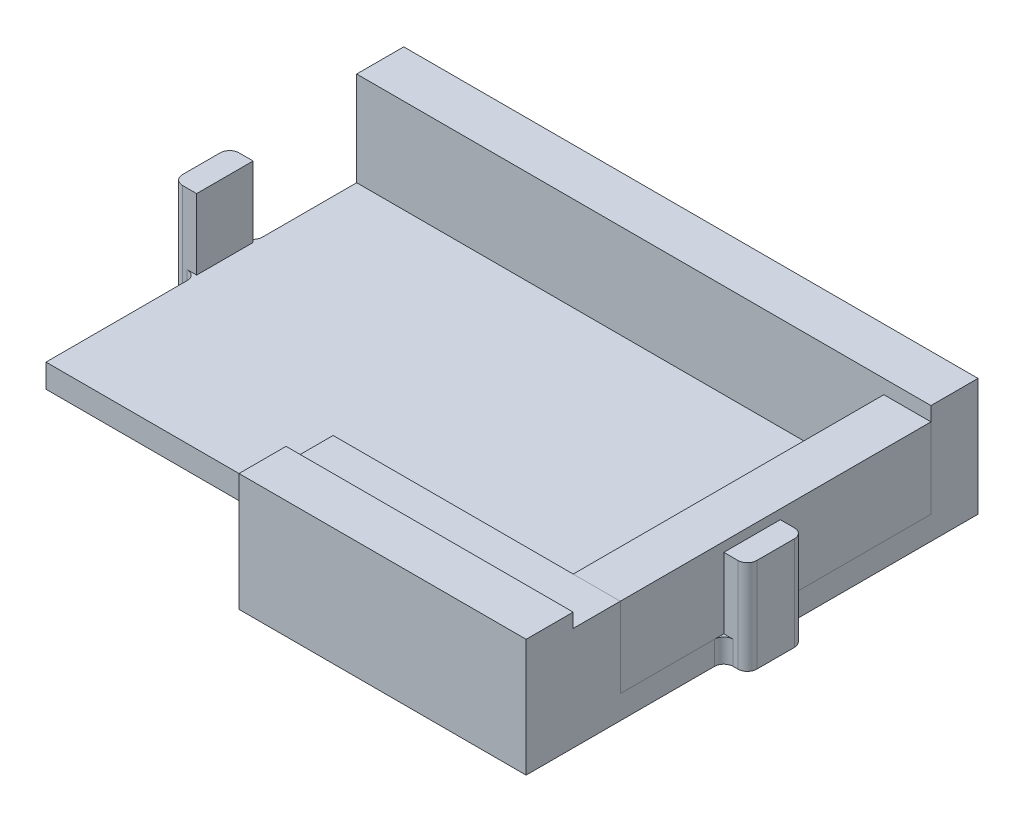
from build123d import *

# Parameters (mm, degrees)
BOSS_EXTRUDE1_DEPTH = 2.5
SKETCH2_W           = 61
SKETCH2_H           = 5
SKETCH2_W_2         = 30.5
BOSS_EXTRUDE2_DEPTH = 10
CUT_EXTRUDE1_DEPTH  = 1
SKETCH5_W           = 2.5
SKETCH5_H           = 6
BOSS_EXTRUDE3_DEPTH = 10
FILLET4_R           = 1
SKETCH6_W           = 30.5
SKETCH6_H           = 5
BOSS_EXTRUDE4_DEPTH = 8.5
SKETCH7_W           = 5
SKETCH7_H           = 33
BOSS_EXTRUDE5_DEPTH = 8.5


with BuildPart() as part:
    # Sketch1 → Boss-Extrude1 (new body)
    with BuildSketch(Plane(origin=(0, 0, 0), x_dir=(1, 0, 0), z_dir=(0, 1, 0))):
        Polygon((0, 10), (30.5, 10), (30.5, 0), (61, 0), (61, 48), (0, 48), align=None)
    extrude(amount=BOSS_EXTRUDE1_DEPTH)

    # Sketch2 → Boss-Extrude2 (add)
    with BuildSketch(Plane(origin=(0, 2.5, 0), x_dir=(1, 0, 0), z_dir=(0, 1, 0))):
        with Locations((30.5, 45.5)):
            Rectangle(SKETCH2_W, SKETCH2_H)
        with Locations((45.75, 2.5)):
            Rectangle(SKETCH2_W_2, SKETCH2_H)
    extrude(amount=BOSS_EXTRUDE2_DEPTH)

    # Sketch3 → Cut-Extrude1 (cut)
    with BuildSketch(Plane.XZ):
        with BuildLine():
            Line((38.1875, -27), (39.6, -27))
            Line((39.6, -27), (39.6, -24.8421875))
            add(Edge.make_bspline(
                [(39.6, -24.8421875), (39.602615405, -24.769084793), (39.607534256, -24.631598895), (39.645917421, -24.438286667), (39.71249642, -24.273057168), (39.80650625, -24.137413973), (39.920250057, -24.03091493), (40.049992557, -23.954750809), (40.194402262, -23.908778619), (40.294972194, -23.902988305), (40.346875, -23.9)],
                knots=[0, 0, 0, 0, 0.000219202, 0.000412257, 0.000588099, 0.000749771, 0.000903445, 0.001051907, 0.001197689, 0.001353164, 0.001353164, 0.001353164, 0.001353164], degree=3))
            add(Edge.make_bspline(
                [(40.346875, -23.9), (40.400811886, -23.903069829), (40.505370426, -23.9090208), (40.654616604, -23.95331831), (40.785818729, -24.030620386), (40.898267418, -24.137525593), (40.989912112, -24.272508914), (41.055867465, -24.436263579), (41.094160201, -24.627408298), (41.097981983, -24.763877569), (41.1, -24.8359375)],
                knots=[0, 0, 0, 0, 0.000161694, 0.00031345, 0.000461912, 0.000614446, 0.000775232, 0.000947589, 0.001140645, 0.001356632, 0.001356632, 0.001356632, 0.001356632], degree=3))
            Line((41.1, -24.8359375), (41.1, -30.7484375))
            add(Edge.make_bspline(
                [(41.1, -30.7484375), (41.099564666, -30.789608087), (41.098725346, -30.868984644), (41.087679787, -30.98393408), (41.069116088, -31.089395785), (41.044395541, -31.186415943), (41.011489006, -31.273687026), (40.972763577, -31.35292309), (40.925545184, -31.42249894), (40.851306001, -31.502978541), (40.733925262, -31.585343097), (40.562936526, -31.653276145), (40.358565351, -31.693106891), (40.211651668, -31.697592735), (40.1328125, -31.7)],
                knots=[0, 0, 0, 0, 0.000123477, 0.000238063, 0.000345954, 0.000444491, 0.000537941, 0.000625288, 0.000708497, 0.00078922, 0.000952693, 0.001133464, 0.001337549, 0.001573905, 0.001573905, 0.001573905, 0.001573905], degree=3))
            Line((40.1328125, -31.7), (38.1734375, -31.7))
            add(Edge.make_bspline(
                [(38.1734375, -31.7), (38.103112581, -31.700035372), (37.96658071, -31.700104044), (37.768157568, -31.691054163), (37.58205737, -31.681244136), (37.408685819, -31.664781958), (37.247289379, -31.647623515), (37.099076931, -31.62146964), (36.962560228, -31.594754723), (36.876957605, -31.570836449), (36.8359375, -31.559375)],
                knots=[0, 0, 0, 0, 0.000210943, 0.000409535, 0.000595793, 0.000769933, 0.000931959, 0.001082487, 0.001221304, 0.001349028, 0.001349028, 0.001349028, 0.001349028], degree=3))
            add(Edge.make_bspline(
                [(36.8359375, -31.559375), (36.758174787, -31.535693231), (36.605197894, -31.48910582), (36.390091341, -31.388381046), (36.189773634, -31.269615451), (36.006592335, -31.12861923), (35.842172885, -30.96773624), (35.699559897, -30.788048857), (35.576231309, -30.592456035), (35.474550885, -30.379737692), (35.397163841, -30.150698292), (35.341005355, -29.908428323), (35.305483612, -29.652613392), (35.301855407, -29.477202426), (35.3, -29.3875)],
                knots=[0, 0, 0, 0, 0.000243595, 0.000479206, 0.000710461, 0.000941103, 0.001170924, 0.00139884, 0.001627734, 0.001863257, 0.002104389, 0.002351501, 0.002608498, 0.002877471, 0.002877471, 0.002877471, 0.002877471], degree=3))
            add(Edge.make_bspline(
                [(35.3, -29.3875), (35.301809825, -29.292586825), (35.30533284, -29.107828413), (35.341011258, -28.839627251), (35.395696925, -28.588344436), (35.476429153, -28.355502686), (35.577363674, -28.139551849), (35.704023887, -27.942951805), (35.851833656, -27.762963601), (36.023207918, -27.601603438), (36.217200455, -27.458365944), (36.433788728, -27.334655233), (36.673512874, -27.232454742), (36.933425896, -27.145634461), (37.216328859, -27.081746386), (37.519917531, -27.032769881), (37.84636014, -27.005079255), (38.071303311, -27.001730061), (38.1875, -27)],
                knots=[0, 0, 0, 0, 0.000284585, 0.000553975, 0.000810225, 0.00105482, 0.001291754, 0.001523642, 0.001754511, 0.001988834, 0.002227902, 0.002476359, 0.002735282, 0.003008523, 0.003297327, 0.003604298, 0.003930513, 0.004279076, 0.004279076, 0.004279076, 0.004279076], degree=3))
        make_face()
        with BuildLine():
            Line((38.5609375, -30.5), (39.6, -30.5))
            Line((39.6, -30.5), (39.6, -28.2))
            Line((39.6, -28.2), (38.5609375, -28.2))
            add(Edge.make_bspline(
                [(38.5609375, -28.2), (38.473925807, -28.201685184), (38.306945409, -28.204919149), (38.067107498, -28.224188963), (37.84970512, -28.25980799), (37.65410835, -28.309033712), (37.480223381, -28.3740791), (37.327553707, -28.457520614), (37.19637362, -28.559225985), (37.088067853, -28.680511212), (37.001621577, -28.82004504), (36.943027083, -28.981175779), (36.906595982, -29.161394296), (36.902263617, -29.288352923), (36.9, -29.3546875)],
                knots=[0, 0, 0, 0, 0.000261054, 0.000500978, 0.000721119, 0.000921217, 0.001105194, 0.001276535, 0.001441259, 0.001600603, 0.001761927, 0.00193054, 0.002112254, 0.002311084, 0.002311084, 0.002311084, 0.002311084], degree=3))
            add(Edge.make_bspline(
                [(36.9, -29.3546875), (36.903364233, -29.434236925), (36.909848384, -29.587558781), (36.966431543, -29.805808259), (37.057238421, -30.003435042), (37.149400887, -30.111694511), (37.1953125, -30.165625)],
                knots=[0, 0, 0, 0, 0.000238239, 0.000459177, 0.000672331, 0.000883921, 0.000883921, 0.000883921, 0.000883921], degree=3))
            add(Edge.make_bspline(
                [(37.1953125, -30.165625), (37.225735979, -30.19276864), (37.290030891, -30.250132162), (37.408815453, -30.317269388), (37.54843091, -30.373136489), (37.708729079, -30.419369207), (37.890973375, -30.456831222), (38.095231339, -30.482248599), (38.321103054, -30.498011146), (38.47861699, -30.499317348), (38.5609375, -30.5)],
                knots=[0, 0, 0, 0, 0.000122035, 0.000257901, 0.000406462, 0.000572587, 0.000757676, 0.00096408, 0.001189621, 0.001436541, 0.001436541, 0.001436541, 0.001436541], degree=3))
        make_face(mode=Mode.SUBTRACT)
        with BuildLine():
            add(Edge.make_bspline(
                [(27.3953125, -26.4515625), (27.397434395, -26.389433762), (27.401815522, -26.261155035), (27.438676119, -26.066027702), (27.49508646, -25.862986158), (27.575462199, -25.654509555), (27.676999221, -25.441216064), (27.810927351, -25.232591398), (27.966003207, -25.022936194), (28.147847897, -24.817903952), (28.356369794, -24.622072842), (28.59422462, -24.445271264), (28.857924229, -24.287111598), (29.147826391, -24.149406865), (29.463719448, -24.035657986), (29.807343765, -23.957565551), (30.175103983, -23.907880656), (30.428998104, -23.902673778), (30.559375, -23.9)],
                knots=[0, 0, 0, 0, 0.000186259, 0.000384573, 0.000593838, 0.000817864, 0.001054066, 0.001301178, 0.001560242, 0.001835849, 0.002122179, 0.002416867, 0.002723153, 0.003043252, 0.003378327, 0.003728149, 0.004098518, 0.004489455, 0.004489455, 0.004489455, 0.004489455], degree=3))
            add(Edge.make_bspline(
                [(30.559375, -23.9), (30.658907566, -23.900818023), (30.853542013, -23.902417653), (31.138651795, -23.926098172), (31.410314201, -23.958436313), (31.668437928, -24.009492265), (31.91383369, -24.073164845), (32.148411511, -24.150895125), (32.370734316, -24.246731815), (32.582544659, -24.358413872), (32.786445998, -24.485270243), (32.979262764, -24.63299341), (33.165986579, -24.797359597), (33.279688705, -24.920302684), (33.3375, -24.9828125)],
                knots=[0, 0, 0, 0, 0.000298503, 0.000583718, 0.000857758, 0.00111884, 0.001372379, 0.001617951, 0.001859431, 0.002097763, 0.002335766, 0.002578894, 0.002825695, 0.003080976, 0.003080976, 0.003080976, 0.003080976], degree=3))
            add(Edge.make_bspline(
                [(33.3375, -24.9828125), (33.387732238, -25.045256239), (33.488415919, -25.170416213), (33.62664404, -25.369767653), (33.751305978, -25.581322722), (33.864560031, -25.802969389), (33.96889525, -26.032668078), (34.057049874, -26.271575372), (34.132994172, -26.518144216), (34.192776415, -26.77262262), (34.24219802, -27.034713776), (34.275782698, -27.304499098), (34.296930981, -27.58246952), (34.298966516, -27.770273188), (34.3, -27.865625)],
                knots=[0, 0, 0, 0, 0.000240371, 0.000481791, 0.000726984, 0.000976461, 0.001228237, 0.001483351, 0.001739872, 0.002001749, 0.002267144, 0.002539633, 0.002816941, 0.003102946, 0.003102946, 0.003102946, 0.003102946], degree=3))
            add(Edge.make_bspline(
                [(34.3, -27.865625), (34.296928776, -28.018393355), (34.290935568, -28.316506669), (34.237641938, -28.750738581), (34.155057159, -29.161415944), (34.034040456, -29.546173325), (33.88237364, -29.905712762), (33.700578841, -30.238948675), (33.488694914, -30.545554745), (33.247756976, -30.823816255), (32.981430376, -31.072732337), (32.692976857, -31.291699142), (32.381102483, -31.475879662), (32.05203128, -31.631243154), (31.706067235, -31.751129862), (31.347662006, -31.837256518), (30.978149733, -31.890278039), (30.727778247, -31.896741619), (30.6015625, -31.9)],
                knots=[0, 0, 0, 0, 0.000458135, 0.000894008, 0.001310458, 0.001713222, 0.002101811, 0.002479406, 0.002849985, 0.003217754, 0.003581454, 0.003941769, 0.004301917, 0.004666091, 0.005031762, 0.005398231, 0.005770569, 0.006149084, 0.006149084, 0.006149084, 0.006149084], degree=3))
            add(Edge.make_bspline(
                [(30.6015625, -31.9), (30.524441789, -31.898742886), (30.37209357, -31.896259519), (30.146868459, -31.878236684), (29.927344507, -31.851668844), (29.715127789, -31.807665956), (29.508340081, -31.757818429), (29.309085734, -31.692186568), (29.115241089, -31.618473757), (28.929616127, -31.530224099), (28.752874019, -31.433744499), (28.58541226, -31.332208627), (28.428296632, -31.226138053), (28.282641161, -31.112876748), (28.146773866, -30.995181346), (28.023157809, -30.870413965), (27.907947472, -30.742735672), (27.806217947, -30.608384363), (27.713796985, -30.473947596), (27.635979163, -30.338426372), (27.567750702, -30.206018755), (27.513878594, -30.074398002), (27.468222606, -29.946218289), (27.43961528, -29.818620064), (27.419205469, -29.693361827), (27.416809536, -29.609975649), (27.415625, -29.56875)],
                knots=[0, 0, 0, 0, 0.000231334, 0.00045699, 0.000677541, 0.000894188, 0.001106785, 0.001315308, 0.001523067, 0.001728564, 0.001931328, 0.002126947, 0.002315899, 0.002499671, 0.002680172, 0.002854739, 0.00302628, 0.003195665, 0.003359913, 0.003515349, 0.003664189, 0.003806376, 0.003941765, 0.004071763, 0.004198161, 0.004321757, 0.004321757, 0.004321757, 0.004321757], degree=3))
            add(Edge.make_bspline(
                [(27.415625, -29.56875), (27.418216573, -29.525307673), (27.423326947, -29.439642884), (27.458565709, -29.31483296), (27.519738515, -29.199264042), (27.601639003, -29.094485493), (27.700373583, -29.005106438), (27.812919531, -28.94061161), (27.935086452, -28.898330021), (28.020481916, -28.894263038), (28.0640625, -28.8921875)],
                knots=[0, 0, 0, 0, 0.000130289, 0.000256919, 0.00038551, 0.00052022, 0.000654131, 0.000782237, 0.000907247, 0.001037535, 0.001037535, 0.001037535, 0.001037535], degree=3))
            add(Edge.make_bspline(
                [(28.0640625, -28.8921875), (28.11106611, -28.893946378), (28.200179439, -28.897281004), (28.324887939, -28.922962447), (28.43172227, -28.968196434), (28.520138472, -29.036800167), (28.598928401, -29.127534222), (28.680965048, -29.239061767), (28.76480885, -29.378834016), (28.82022041, -29.481020091), (28.85, -29.5359375)],
                knots=[0, 0, 0, 0, 0.000140937, 0.0002672, 0.000379841, 0.000485781, 0.000599715, 0.000739408, 0.000900732, 0.00108816, 0.00108816, 0.00108816, 0.00108816], degree=3))
            add(Edge.make_bspline(
                [(28.85, -29.5359375), (28.901211449, -29.62825275), (29.000008605, -29.806347382), (29.17412368, -30.045485691), (29.362747316, -30.247263649), (29.564423253, -30.415768884), (29.788184683, -30.545230891), (30.034861588, -30.636014618), (30.305541211, -30.689354721), (30.49350599, -30.696373491), (30.590625, -30.7)],
                knots=[0, 0, 0, 0, 0.000316494, 0.00061058, 0.000884727, 0.001143409, 0.001396133, 0.001656185, 0.001928603, 0.002219832, 0.002219832, 0.002219832, 0.002219832], degree=3))
            add(Edge.make_bspline(
                [(30.590625, -30.7), (30.668904848, -30.698261598), (30.82268842, -30.694846445), (31.04630224, -30.65733031), (31.25832523, -30.59983937), (31.457865159, -30.518199368), (31.645312593, -30.412783723), (31.819870085, -30.282917498), (31.983147995, -30.131118747), (32.131501037, -29.954683731), (32.265655206, -29.757941294), (32.383149221, -29.541347392), (32.482331498, -29.304856673), (32.560445287, -29.048469195), (32.623417413, -28.772809997), (32.668074561, -28.477773945), (32.694558587, -28.162986086), (32.69815336, -27.946927256), (32.7, -27.8359375)],
                knots=[0, 0, 0, 0, 0.00023463, 0.000460939, 0.000678149, 0.000892576, 0.001105959, 0.00132159, 0.0015438, 0.001773275, 0.002011637, 0.002257049, 0.002511257, 0.002779611, 0.003060101, 0.003358869, 0.003674053, 0.004006998, 0.004006998, 0.004006998, 0.004006998], degree=3))
            add(Edge.make_bspline(
                [(32.7, -27.8359375), (32.698833253, -27.760931136), (32.69655527, -27.614486963), (32.686542363, -27.399076416), (32.665280534, -27.193891054), (32.640015517, -26.997520446), (32.603466249, -26.811507385), (32.56041258, -26.635005369), (32.508120395, -26.468274026), (32.449927797, -26.310651199), (32.381075769, -26.16367205), (32.310818082, -26.023934919), (32.230340137, -25.89514944), (32.143127881, -25.776982149), (32.04986706, -25.667643547), (31.950588506, -25.567776514), (31.843489711, -25.478402803), (31.693281427, -25.371883839), (31.489732233, -25.262067222), (31.225379638, -25.167679785), (30.94102803, -25.109994376), (30.744546838, -25.103388752), (30.64375, -25.1)],
                knots=[0, 0, 0, 0, 0.000225049, 0.000439391, 0.000646638, 0.000843749, 0.001033127, 0.00121503, 0.001388495, 0.001557108, 0.001718621, 0.001875159, 0.002026044, 0.002173549, 0.002315401, 0.002456823, 0.002595463, 0.002733327, 0.003008793, 0.00328606, 0.00357288, 0.003875025, 0.003875025, 0.003875025, 0.003875025], degree=3))
            add(Edge.make_bspline(
                [(30.64375, -25.1), (30.588489942, -25.100593687), (30.479768196, -25.10176174), (30.320612286, -25.120042027), (30.167791943, -25.146807154), (30.020831754, -25.181431319), (29.881027725, -25.230719935), (29.748093101, -25.290387087), (29.620719037, -25.359159796), (29.500104525, -25.438731593), (29.387498939, -25.530229656), (29.281140777, -25.630630295), (29.180145082, -25.7394719), (29.090208217, -25.861250123), (29.005084319, -25.991365687), (28.927399639, -26.131868605), (28.856565342, -26.282083188), (28.816988353, -26.387202497), (28.796875, -26.440625)],
                knots=[0, 0, 0, 0, 0.000165691, 0.00032599, 0.000479863, 0.000631071, 0.000778327, 0.000923808, 0.001067838, 0.001212147, 0.001356609, 0.001502516, 0.001650715, 0.001801341, 0.00195606, 0.002116929, 0.002282591, 0.002453783, 0.002453783, 0.002453783, 0.002453783], degree=3))
            add(Edge.make_bspline(
                [(28.796875, -26.440625), (28.779923737, -26.49039154), (28.747176989, -26.586531418), (28.687691881, -26.720620223), (28.623103662, -26.841257823), (28.553013155, -26.948413623), (28.467251361, -27.040271656), (28.354687836, -27.10142068), (28.221471962, -27.137410906), (28.125771742, -27.141552673), (28.075, -27.14375)],
                knots=[0, 0, 0, 0, 0.000157658, 0.000304566, 0.000439494, 0.000567771, 0.000688206, 0.000812048, 0.000946623, 0.0010987, 0.0010987, 0.0010987, 0.0010987], degree=3))
            add(Edge.make_bspline(
                [(28.075, -27.14375), (28.029903738, -27.141508843), (27.941198654, -27.137100449), (27.814095489, -27.097167016), (27.695459856, -27.036124439), (27.592900486, -26.94770771), (27.503846104, -26.84423332), (27.441625361, -26.723661053), (27.401582242, -26.591574897), (27.397448484, -26.499262112), (27.3953125, -26.4515625)],
                knots=[0, 0, 0, 0, 0.000134955, 0.000265459, 0.000396159, 0.000532599, 0.000669038, 0.000803231, 0.000936731, 0.001079467, 0.001079467, 0.001079467, 0.001079467], degree=3))
        make_face()
        with BuildLine():
            Line((22.609375, -24), (24.95625, -24))
            add(Edge.make_bspline(
                [(24.95625, -24), (24.997415558, -24.00044181), (25.076263915, -24.001288052), (25.190254306, -24.012085866), (25.294261467, -24.031717368), (25.390986138, -24.053200458), (25.477078179, -24.087562104), (25.555956611, -24.125038751), (25.62369368, -24.17349785), (25.705027455, -24.244824252), (25.786617851, -24.360816671), (25.853445579, -24.530393885), (25.892921937, -24.732596084), (25.897538073, -24.878457572), (25.9, -24.95625)],
                knots=[0, 0, 0, 0, 0.000123477, 0.000236507, 0.000342861, 0.000441013, 0.000533001, 0.000620348, 0.000702271, 0.000781943, 0.00094415, 0.001121437, 0.001325521, 0.001558758, 0.001558758, 0.001558758, 0.001558758], degree=3))
            Line((25.9, -24.95625), (25.9, -30.74375))
            add(Edge.make_bspline(
                [(25.9, -30.74375), (25.897849137, -30.823174119), (25.893850401, -30.970833982), (25.851264008, -31.174607226), (25.784726551, -31.345849509), (25.682049495, -31.481443137), (25.547883107, -31.584300205), (25.37896778, -31.651640477), (25.178606033, -31.693462879), (25.033573246, -31.697726747), (24.95625, -31.7)],
                knots=[0, 0, 0, 0, 0.000237916, 0.000442317, 0.000621644, 0.000784459, 0.000946033, 0.001122478, 0.00132535, 0.001557027, 0.001557027, 0.001557027, 0.001557027], degree=3))
            Line((24.95625, -31.7), (22.46875, -31.7))
            add(Edge.make_bspline(
                [(22.46875, -31.7), (22.380195084, -31.699016417), (22.209243581, -31.697117653), (21.961598382, -31.684980581), (21.732143127, -31.663431667), (21.51900852, -31.632807584), (21.320018105, -31.589552454), (21.133341895, -31.529839763), (20.956539538, -31.455218626), (20.846817504, -31.392276194), (20.7921875, -31.3609375)],
                knots=[0, 0, 0, 0, 0.000265666, 0.000512858, 0.000743584, 0.000956824, 0.001158502, 0.001353689, 0.001544083, 0.001732881, 0.001732881, 0.001732881, 0.001732881], degree=3))
            add(Edge.make_bspline(
                [(20.7921875, -31.3609375), (20.746859819, -31.332552516), (20.65620876, -31.275785243), (20.530170425, -31.176793863), (20.411485761, -31.067709117), (20.301206611, -30.948440861), (20.201696205, -30.819051469), (20.113725938, -30.682710597), (20.038552778, -30.539936674), (19.9755159, -30.39122794), (19.927319562, -30.236725481), (19.893400873, -30.077676468), (19.86982407, -29.914766049), (19.868072242, -29.804251604), (19.8671875, -29.7484375)],
                knots=[0, 0, 0, 0, 0.000160352, 0.00032069, 0.000479927, 0.000643579, 0.000807344, 0.000969008, 0.001129763, 0.001290822, 0.001452916, 0.001614429, 0.001778395, 0.001945699, 0.001945699, 0.001945699, 0.001945699], degree=3))
            add(Edge.make_bspline(
                [(19.8671875, -29.7484375), (19.870692334, -29.654400526), (19.877531182, -29.470909822), (19.933683369, -29.205969805), (20.024066425, -28.960027801), (20.154910751, -28.735520326), (20.321165278, -28.529771878), (20.525259912, -28.345168119), (20.764690162, -28.179226249), (20.943500543, -28.090948264), (21.0359375, -28.0453125)],
                knots=[0, 0, 0, 0, 0.000281874, 0.00055001, 0.000808598, 0.00106481, 0.001325916, 0.001599086, 0.001887742, 0.002196663, 0.002196663, 0.002196663, 0.002196663], degree=3))
            add(Edge.make_bspline(
                [(21.0359375, -28.0453125), (20.973698003, -28.02467476), (20.852230585, -27.984397878), (20.67828039, -27.913252976), (20.515311339, -27.837497473), (20.364676165, -27.753142363), (20.227017994, -27.660166577), (20.099479567, -27.562302095), (19.985422759, -27.455642433), (19.882821782, -27.34231557), (19.792280825, -27.222104467), (19.713097522, -27.094805268), (19.648309964, -26.95964993), (19.591912181, -26.818800434), (19.553102419, -26.668797324), (19.520366123, -26.513198889), (19.504051782, -26.349824039), (19.501365307, -26.239089474), (19.5, -26.1828125)],
                knots=[0, 0, 0, 0, 0.000196664, 0.000383812, 0.000563445, 0.000735547, 0.000901091, 0.001061429, 0.001217311, 0.001368873, 0.001519499, 0.001668232, 0.001817776, 0.00196866, 0.002122556, 0.002281901, 0.002445307, 0.002614173, 0.002614173, 0.002614173, 0.002614173], degree=3))
            add(Edge.make_bspline(
                [(19.5, -26.1828125), (19.503461017, -26.078793647), (19.510295392, -25.873390428), (19.577916521, -25.574954709), (19.680478222, -25.290689567), (19.828282828, -25.027648393), (20.01054828, -24.788969357), (20.223389643, -24.580143173), (20.466711789, -24.404811205), (20.647447054, -24.318666901), (20.7390625, -24.275)],
                knots=[0, 0, 0, 0, 0.0003116, 0.000615309, 0.000913402, 0.001215563, 0.001516514, 0.001811529, 0.002107234, 0.002411219, 0.002411219, 0.002411219, 0.002411219], degree=3))
            add(Edge.make_bspline(
                [(20.7390625, -24.275), (20.799670964, -24.250654322), (20.923446966, -24.200935019), (21.119452541, -24.142151292), (21.327917118, -24.095542104), (21.550380522, -24.060367094), (21.788509127, -24.031603193), (22.045648513, -24.01451212), (22.3212055, -24.000714391), (22.511438019, -24.000242792), (22.609375, -24)],
                knots=[0, 0, 0, 0, 0.000195868, 0.000400006, 0.00061304, 0.000836264, 0.001075423, 0.001332359, 0.001609203, 0.00190297, 0.00190297, 0.00190297, 0.00190297], degree=3))
        make_face()
        with BuildLine():
            Line((22.7546875, -27.4), (24.4, -27.4))
            Line((24.4, -27.4), (24.4, -25.2))
            Line((24.4, -25.2), (22.7015625, -25.2))
            add(Edge.make_bspline(
                [(22.7015625, -25.2), (22.636960258, -25.200986697), (22.511797831, -25.202898354), (22.330224186, -25.215098838), (22.161051944, -25.236506353), (22.004068057, -25.268094391), (21.859328646, -25.306612649), (21.726069456, -25.352570319), (21.60797199, -25.411598943), (21.499334317, -25.474753655), (21.405751026, -25.550623204), (21.323727607, -25.633772569), (21.253278307, -25.725586969), (21.198095328, -25.827322133), (21.152893651, -25.93708658), (21.122634393, -26.055966699), (21.103312621, -26.183222172), (21.101122499, -26.270759598), (21.1, -26.315625)],
                knots=[0, 0, 0, 0, 0.000193807, 0.000375487, 0.000545649, 0.000704993, 0.000855465, 0.000994834, 0.001126909, 0.001250978, 0.001371037, 0.001487052, 0.001600803, 0.001716902, 0.001833254, 0.001956047, 0.002083991, 0.002218511, 0.002218511, 0.002218511, 0.002218511], degree=3))
            add(Edge.make_bspline(
                [(21.1, -26.315625), (21.100918247, -26.361559449), (21.102701925, -26.45078631), (21.12455026, -26.579321889), (21.154243394, -26.699068274), (21.200228922, -26.808598692), (21.26045565, -26.907048509), (21.331157689, -26.997968126), (21.41621538, -27.077645787), (21.514602046, -27.147444096), (21.626628063, -27.205245528), (21.748964547, -27.259961896), (21.886078313, -27.302656472), (22.035457789, -27.338174392), (22.197245874, -27.36607614), (22.371403958, -27.386717839), (22.558741209, -27.396598962), (22.688012701, -27.398842726), (22.7546875, -27.4)],
                knots=[0, 0, 0, 0, 0.000137642, 0.000267367, 0.00039016, 0.000507108, 0.000622066, 0.000735538, 0.000851595, 0.000970386, 0.001096214, 0.001229164, 0.001371968, 0.001526213, 0.00168959, 0.001864213, 0.002052031, 0.002252086, 0.002252086, 0.002252086, 0.002252086], degree=3))
        make_face(mode=Mode.SUBTRACT)
        with BuildLine():
            Line((24.4, -30.5), (24.4, -28.5))
            Line((24.4, -28.5), (22.9515625, -28.5))
            add(Edge.make_bspline(
                [(22.9515625, -28.5), (22.858796315, -28.500722054), (22.683904339, -28.502083342), (22.438614122, -28.524429591), (22.226048411, -28.557188245), (22.043688346, -28.604703837), (21.885532563, -28.672434831), (21.751561104, -28.76811269), (21.635091924, -28.887969958), (21.576861926, -28.983577247), (21.546875, -29.0328125)],
                knots=[0, 0, 0, 0, 0.000278195, 0.000524481, 0.000738201, 0.000922795, 0.001088582, 0.001251149, 0.001413597, 0.001586074, 0.001586074, 0.001586074, 0.001586074], degree=3))
            add(Edge.make_bspline(
                [(21.546875, -29.0328125), (21.525855906, -29.07027428), (21.483996925, -29.144878444), (21.442815471, -29.267652577), (21.414358889, -29.396077388), (21.412088661, -29.484733047), (21.4109375, -29.5296875)],
                knots=[0, 0, 0, 0, 0.000128591, 0.000256086, 0.000386935, 0.000521537, 0.000521537, 0.000521537, 0.000521537], degree=3))
            add(Edge.make_bspline(
                [(21.4109375, -29.5296875), (21.411837646, -29.57665573), (21.413557483, -29.666394103), (21.434794111, -29.794758858), (21.466882615, -29.911008904), (21.512553098, -30.016103823), (21.571737287, -30.108862221), (21.645633752, -30.18873812), (21.732142536, -30.256308628), (21.832864846, -30.311294452), (21.946751108, -30.35589558), (22.073274986, -30.394531848), (22.213647079, -30.427629539), (22.367803007, -30.452816228), (22.535414186, -30.475892536), (22.716536468, -30.488203364), (22.911339088, -30.498589694), (23.045815945, -30.499518067), (23.115625, -30.5)],
                knots=[0, 0, 0, 0, 0.000140764, 0.000268946, 0.000389137, 0.000501778, 0.000611431, 0.000717589, 0.000826674, 0.000939282, 0.001060565, 0.001193018, 0.0013359, 0.001492851, 0.001661464, 0.001843258, 0.002037235, 0.002246633, 0.002246633, 0.002246633, 0.002246633], degree=3))
            Line((23.115625, -30.5), (24.4, -30.5))
        make_face(mode=Mode.SUBTRACT)
    extrude(amount=-CUT_EXTRUDE1_DEPTH, mode=Mode.SUBTRACT)

    # Sketch5 → Boss-Extrude3 (add)
    with BuildSketch(Plane.XZ):
        with Locations((-1.25, -29)):
            Rectangle(SKETCH5_W, SKETCH5_H)
        with Locations((62.25, -24)):
            Rectangle(SKETCH5_W, SKETCH5_H)
    extrude(amount=-BOSS_EXTRUDE3_DEPTH)

    # Fillet4
    fillet4_edges = [part.edges().sort_by_distance(p)[0] for p in [
        (0, 1.25, -26),
        (0, 1.25, -32),
        (-2.5, 5, -32),
        (-2.5, 5, -26),
        (61, 1.25, -27),
        (61, 1.25, -21),
        (63.5, 5, -21),
        (63.5, 5, -27),
    ]]
    fillet(fillet4_edges, radius=FILLET4_R)

    # Sketch6 → Boss-Extrude4 (add)
    with BuildSketch(Plane(origin=(0, 2.5, 0), x_dir=(1, 0, 0), z_dir=(0, 1, 0))):
        with Locations((45.75, 7.5)):
            Rectangle(SKETCH6_W, SKETCH6_H)
    extrude(amount=BOSS_EXTRUDE4_DEPTH)


with BuildPart() as body_2:
    # Sketch7 → Boss-Extrude5 (new body)
    with BuildSketch(Plane(origin=(0, 2.5, 0), x_dir=(1, 0, 0), z_dir=(0, 1, 0))):
        with Locations((58.5, 26.5)):
            Rectangle(SKETCH7_W, SKETCH7_H)
    extrude(amount=BOSS_EXTRUDE5_DEPTH)


solid = Compound([part.part, body_2.part])
